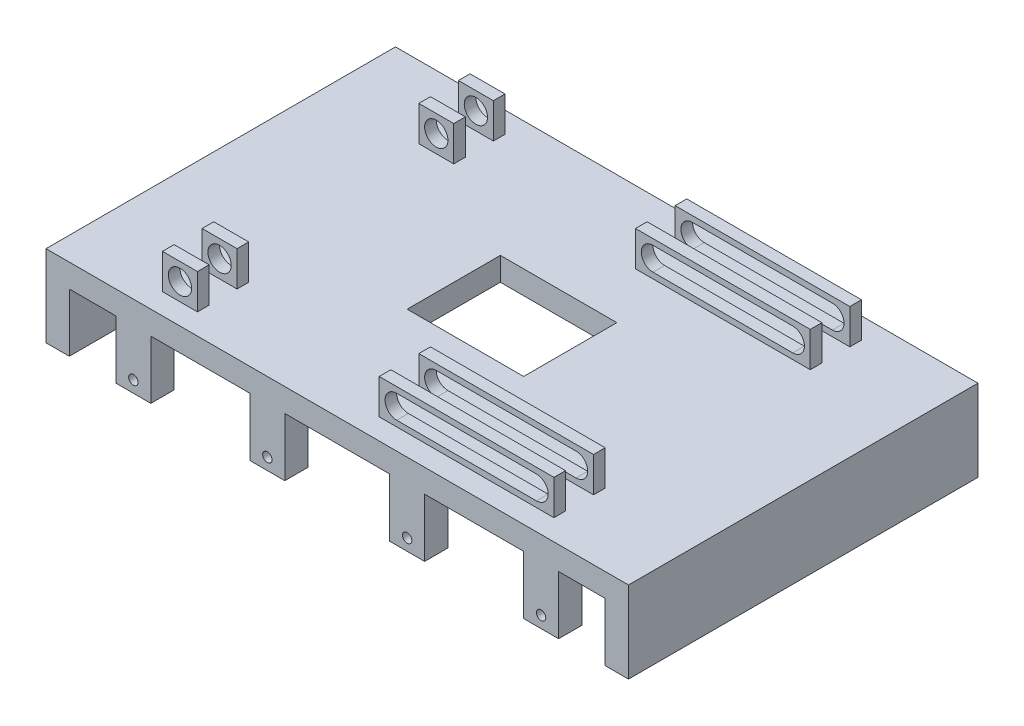
from build123d import *

# Parameters (mm, degrees)
SKETCH1_W               = 250
SKETCH1_H               = 150
SKETCH1_W_2             = 75
SKETCH1_H_2             = 5
SKETCH1_W_3             = 15
BOSS_EXTRUDE2_DEPTH     = 10
SKETCH1_8_W             = 75
SKETCH1_8_H             = 5
SKETCH1_8_W_2           = 15
BOSS_EXTRUDE3_DEPTH     = 25
SKETCH5_W               = 230
SKETCH5_H               = 130
BOSS_EXTRUDE4_DEPTH     = 25
CUT_EXTRUDE2_DEPTH      = 175.387499552
CUT_EXTRUDE2_DEPTH_BACK = 175.387499552
SKETCH7_R               = 5
CUT_EXTRUDE3_DEPTH      = 191.081561441
SKETCH9_W               = 50
SKETCH9_H               = 40
CUT_EXTRUDE4_DEPTH      = 10
CUT_EXTRUDE5_DEPTH      = 197.85019685
CUT_EXTRUDE5_DEPTH_BACK = 197.85019685
SKETCH10_R              = 2
SKETCH10_W              = 42.5
SKETCH10_H              = 25
SKETCH10_W_2            = 20
SKETCH10_W_3            = 45


with BuildPart() as part:
    # Sketch1 → Boss-Extrude2 (new body)
    with BuildSketch(Plane(origin=(0, 0, 0), x_dir=(1, 0, 0), z_dir=(0, 1, 0))):
        Rectangle(SKETCH1_W, SKETCH1_H)
        with Locations((46.5, -63.5)):
            Rectangle(SKETCH1_W_2, SKETCH1_H_2, mode=Mode.SUBTRACT)
        with Locations((-76.5, -63.5)):
            Rectangle(SKETCH1_W_3, SKETCH1_H_2, mode=Mode.SUBTRACT)
        with Locations((-76.5, -46.5)):
            Rectangle(SKETCH1_W_3, SKETCH1_H_2, mode=Mode.SUBTRACT)
        with Locations((46.5, -46.5)):
            Rectangle(SKETCH1_W_2, SKETCH1_H_2, mode=Mode.SUBTRACT)
        with Locations((46.5, 46.5)):
            Rectangle(SKETCH1_W_2, SKETCH1_H_2, mode=Mode.SUBTRACT)
        with Locations((46.5, 63.5)):
            Rectangle(SKETCH1_W_2, SKETCH1_H_2, mode=Mode.SUBTRACT)
        with Locations((-76.5, 63.5)):
            Rectangle(SKETCH1_W_3, SKETCH1_H_2, mode=Mode.SUBTRACT)
        with Locations((-76.5, 46.5)):
            Rectangle(SKETCH1_W_3, SKETCH1_H_2, mode=Mode.SUBTRACT)
    extrude(amount=BOSS_EXTRUDE2_DEPTH)

    # Sketch1_8 → Boss-Extrude3 (add)
    with BuildSketch(Plane(origin=(0, 0, 0), x_dir=(1, 0, 0), z_dir=(0, 1, 0))):
        with Locations((46.5, -63.5)):
            Rectangle(SKETCH1_8_W, SKETCH1_8_H)
        with Locations((-76.5, -63.5)):
            Rectangle(SKETCH1_8_W_2, SKETCH1_8_H)
        with Locations((-76.5, -46.5)):
            Rectangle(SKETCH1_8_W_2, SKETCH1_8_H)
        with Locations((46.5, -46.5)):
            Rectangle(SKETCH1_8_W, SKETCH1_8_H)
        with Locations((46.5, 46.5)):
            Rectangle(SKETCH1_8_W, SKETCH1_8_H)
        with Locations((46.5, 63.5)):
            Rectangle(SKETCH1_8_W, SKETCH1_8_H)
        with Locations((-76.5, 63.5)):
            Rectangle(SKETCH1_8_W_2, SKETCH1_8_H)
        with Locations((-76.5, 46.5)):
            Rectangle(SKETCH1_8_W_2, SKETCH1_8_H)
    extrude(amount=BOSS_EXTRUDE3_DEPTH)

    # Sketch5 → Boss-Extrude4 (add)
    with BuildSketch(Plane.XZ):
        Polygon((-125, 75), (-115, 75), (115, 75), (125, 75), (125, -75), (90, -75), (-90, -75), (-125, -75), align=None)
        Rectangle(SKETCH5_W, SKETCH5_H, mode=Mode.SUBTRACT)
    extrude(amount=BOSS_EXTRUDE4_DEPTH)

    # Sketch7 → Cut-Extrude2 (cut, two sides: drawn at the far end of the back side and taken through both)
    with BuildSketch(Plane(origin=(0, 0, 44), x_dir=(-1, 0, 0), z_dir=(0, 0, -1)).offset(-CUT_EXTRUDE2_DEPTH_BACK)):
        with Locations((76.5, 17.5)):
            Circle(SKETCH7_R)
    extrude(amount=CUT_EXTRUDE2_DEPTH + CUT_EXTRUDE2_DEPTH_BACK, mode=Mode.SUBTRACT)

    # Sketch8 → Cut-Extrude3 (cut, through all)
    with BuildSketch(Plane.XY.offset(66)):
        with BuildLine():
            Line((16.5, 22.5), (76.5, 22.5))
            ThreePointArc((76.5, 22.5), (81.5, 17.5), (76.5, 12.5))
            Line((76.5, 12.5), (16.5, 12.5))
            ThreePointArc((16.5, 12.5), (11.5, 17.5), (16.5, 22.5))
        make_face()
    extrude(amount=-CUT_EXTRUDE3_DEPTH, mode=Mode.SUBTRACT)

    # Sketch9 → Cut-Extrude4 (cut)
    with BuildSketch(Plane(origin=(0, 10, 0), x_dir=(1, 0, 0), z_dir=(0, 1, 0))):
        Rectangle(SKETCH9_W, SKETCH9_H)
    extrude(amount=-CUT_EXTRUDE4_DEPTH, mode=Mode.SUBTRACT)

    # Sketch10 → Cut-Extrude5 (cut, two sides: drawn at the far end of the back side and taken through both)
    with BuildSketch(Plane.XY.offset(75).offset(-CUT_EXTRUDE5_DEPTH_BACK)):
        with Locations((-87.5, -20)):
            Circle(SKETCH10_R)
        with Locations((87.5, -20)):
            Circle(SKETCH10_R)
        with Locations((-30, -20)):
            Circle(SKETCH10_R)
        with Locations((30, -20)):
            Circle(SKETCH10_R)
        with Locations((-58.75, -12.5)):
            Rectangle(SKETCH10_W, SKETCH10_H)
        with Locations((-105, -12.5)):
            Rectangle(SKETCH10_W_2, SKETCH10_H)
        with Locations((0, -12.5)):
            Rectangle(SKETCH10_W_3, SKETCH10_H)
        with Locations((58.75, -12.5)):
            Rectangle(SKETCH10_W, SKETCH10_H)
        with Locations((105, -12.5)):
            Rectangle(SKETCH10_W_2, SKETCH10_H)
    extrude(amount=CUT_EXTRUDE5_DEPTH + CUT_EXTRUDE5_DEPTH_BACK, mode=Mode.SUBTRACT)


solid = part.part
